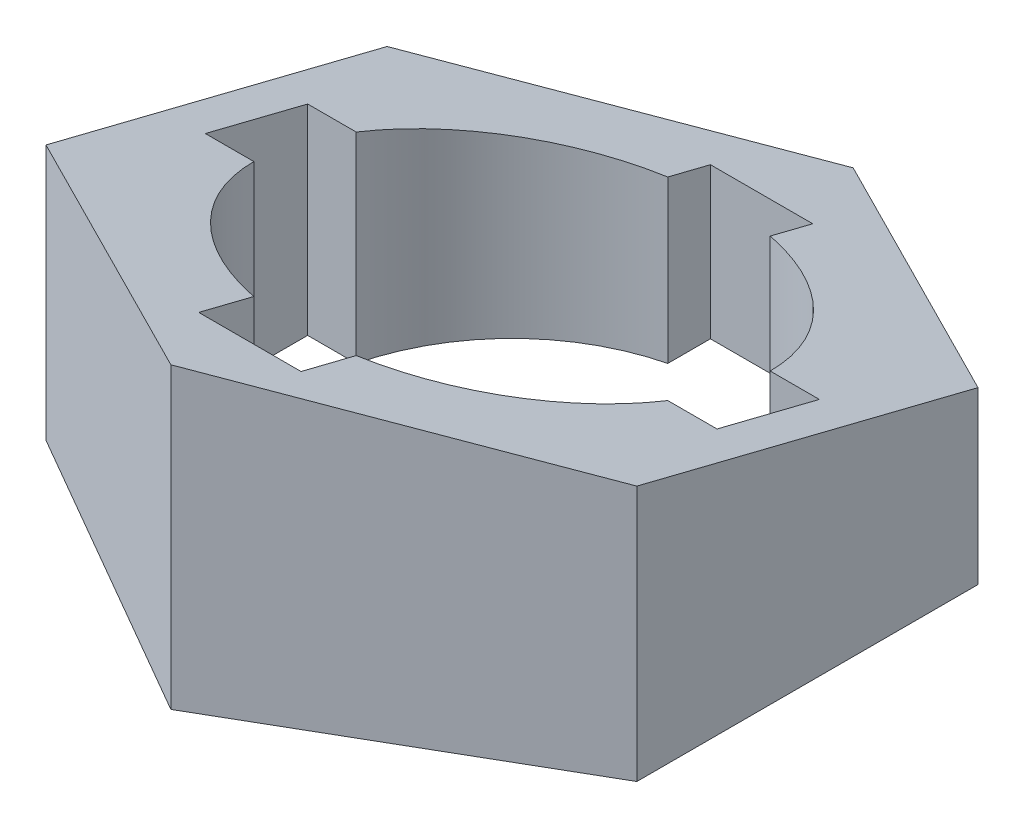
from build123d import *

# Parameters (mm, degrees)
BOSS_EXTRUDE2_DEPTH      = 35
CUT_EXTRUDE8_DEPTH       = 1
CUT_EXTRUDE8_DEPTH_BACK  = 36
CUT_EXTRUDE10_DEPTH      = 1
CUT_EXTRUDE10_DEPTH_BACK = 70.282032303


with BuildPart() as part:
    # Sketch1 → Boss-Extrude2 (new body)
    with BuildSketch(Plane(origin=(0, 0, 0), x_dir=(1, 0, 0), z_dir=(0, 1, 0))):
        Polygon((0, 40), (-34.641016151, 20), (-34.641016151, -20), (0, -40), (34.641016151, -20), (34.641016151, 20), align=None)
    extrude(amount=BOSS_EXTRUDE2_DEPTH)

    # Sketch8 → Cut-Extrude8 (cut, two sides)
    with BuildSketch(Plane(origin=(0, 35, 0), x_dir=(1, 0, 0), z_dir=(0, 1, 0))) as cut_extrude8_sk:
        with BuildLine():
            Line((-6, 29.265974935), (6, 29.265974935))
            Line((6, 29.265974935), (6, 24.269322199))
            ThreePointArc((6, 24.269322199), (17.67766953, 17.67766953), (24.269322199, 6))
            Line((24.269322199, 6), (30.040393537, 6))
            Line((30.040393537, 6), (30.040393537, -6))
            Line((30.040393537, -6), (24.269322199, -6))
            ThreePointArc((24.269322199, -6), (17.67766953, -17.67766953), (6, -24.269322199))
            Line((6, -24.269322199), (6, -30.734025065))
            Line((6, -30.734025065), (-6, -30.734025065))
            Line((-6, -30.734025065), (-6, -24.269322199))
            ThreePointArc((-6, -24.269322199), (-17.67766953, -17.67766953), (-24.269322199, -6))
            Line((-24.269322199, -6), (-29.959606463, -6))
            Line((-29.959606463, -6), (-29.959606463, 6))
            Line((-29.959606463, 6), (-24.269322199, 6))
            ThreePointArc((-24.269322199, 6), (-17.67766953, 17.67766953), (-6, 24.269322199))
            Line((-6, 24.269322199), (-6, 29.265974935))
        make_face()
    extrude(amount=CUT_EXTRUDE8_DEPTH, mode=Mode.SUBTRACT)
    extrude(cut_extrude8_sk.sketch, amount=-CUT_EXTRUDE8_DEPTH_BACK, mode=Mode.SUBTRACT)

    # Sketch9 → Cut-Extrude10 (cut, two sides)
    with BuildSketch(Plane.ZY.offset(34.641016151)) as cut_extrude10_sk:
        Polygon((40, 35), (-40, 15), (-40, 35), (-20, 35), (20, 35), align=None)
    extrude(amount=CUT_EXTRUDE10_DEPTH, mode=Mode.SUBTRACT)
    extrude(cut_extrude10_sk.sketch, amount=-CUT_EXTRUDE10_DEPTH_BACK, mode=Mode.SUBTRACT)


solid = part.part
